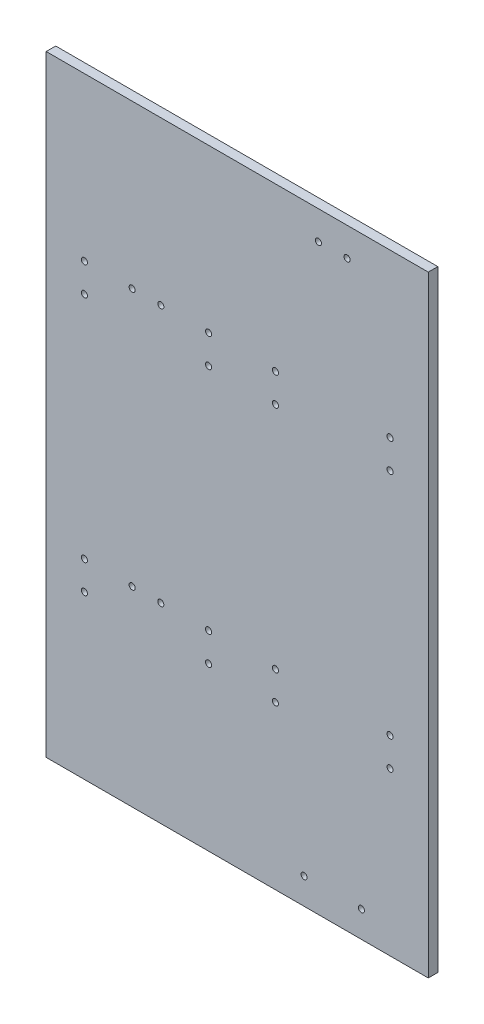
from build123d import *

# Parameters (mm, degrees)
SKETCH1_W           = 200
SKETCH1_H           = 320
BOSS_EXTRUDE1_DEPTH = 5
CUT_EXTRUDE1_REACH  = 7
SKETCH2_R           = 1.6
CUT_EXTRUDE2_REACH  = 7
SKETCH3_R           = 1.6
CUT_EXTRUDE3_REACH  = 7
SKETCH4_R           = 1.6
CUT_EXTRUDE4_REACH  = 7
SKETCH5_R           = 1.6
CUT_EXTRUDE5_REACH  = 7
SKETCH6_R           = 1.6


with BuildPart() as part:
    # Sketch1 → Boss-Extrude1 (new body)
    with BuildSketch(Plane.XY):
        Rectangle(SKETCH1_W, SKETCH1_H)
    extrude(amount=BOSS_EXTRUDE1_DEPTH)

    # Sketch2 → Cut-Extrude1 (cut, up to next)
    with BuildSketch(Plane(origin=(0, 0, 0), x_dir=(-1, 0, 0), z_dir=(0, 0, -1)), mode=Mode.PRIVATE) as cut_extrude1_sk1:
        with Locations((-80, 75)):
            Circle(SKETCH2_R)
    cut_extrude1_tool1 = extrude(cut_extrude1_sk1.sketch, amount=-CUT_EXTRUDE1_REACH, mode=Mode.PRIVATE) & part.part
    add(cut_extrude1_tool1.solids().sort_by_distance((80, 75, 0))[0], mode=Mode.SUBTRACT)
    # Sketch2 → Cut-Extrude1 (cut, up to next)
    with BuildSketch(Plane(origin=(0, 0, 0), x_dir=(-1, 0, 0), z_dir=(0, 0, -1)), mode=Mode.PRIVATE) as cut_extrude1_sk2:
        with Locations((-80, 60)):
            Circle(SKETCH2_R)
    cut_extrude1_tool2 = extrude(cut_extrude1_sk2.sketch, amount=-CUT_EXTRUDE1_REACH, mode=Mode.PRIVATE) & part.part
    add(cut_extrude1_tool2.solids().sort_by_distance((80, 60, 0))[0], mode=Mode.SUBTRACT)
    # Sketch2 → Cut-Extrude1 (cut, up to next)
    with BuildSketch(Plane(origin=(0, 0, 0), x_dir=(-1, 0, 0), z_dir=(0, 0, -1)), mode=Mode.PRIVATE) as cut_extrude1_sk3:
        with Locations((-80, -60)):
            Circle(SKETCH2_R)
    cut_extrude1_tool3 = extrude(cut_extrude1_sk3.sketch, amount=-CUT_EXTRUDE1_REACH, mode=Mode.PRIVATE) & part.part
    add(cut_extrude1_tool3.solids().sort_by_distance((80, -60, 0))[0], mode=Mode.SUBTRACT)
    # Sketch2 → Cut-Extrude1 (cut, up to next)
    with BuildSketch(Plane(origin=(0, 0, 0), x_dir=(-1, 0, 0), z_dir=(0, 0, -1)), mode=Mode.PRIVATE) as cut_extrude1_sk4:
        with Locations((-80, -75)):
            Circle(SKETCH2_R)
    cut_extrude1_tool4 = extrude(cut_extrude1_sk4.sketch, amount=-CUT_EXTRUDE1_REACH, mode=Mode.PRIVATE) & part.part
    add(cut_extrude1_tool4.solids().sort_by_distance((80, -75, 0))[0], mode=Mode.SUBTRACT)
    # Sketch2 → Cut-Extrude1 (cut, up to next)
    with BuildSketch(Plane(origin=(0, 0, 0), x_dir=(-1, 0, 0), z_dir=(0, 0, -1)), mode=Mode.PRIVATE) as cut_extrude1_sk5:
        with Locations((-20, -75)):
            Circle(SKETCH2_R)
    cut_extrude1_tool5 = extrude(cut_extrude1_sk5.sketch, amount=-CUT_EXTRUDE1_REACH, mode=Mode.PRIVATE) & part.part
    add(cut_extrude1_tool5.solids().sort_by_distance((20, -75, 0))[0], mode=Mode.SUBTRACT)
    # Sketch2 → Cut-Extrude1 (cut, up to next)
    with BuildSketch(Plane(origin=(0, 0, 0), x_dir=(-1, 0, 0), z_dir=(0, 0, -1)), mode=Mode.PRIVATE) as cut_extrude1_sk6:
        with Locations((-20, -60)):
            Circle(SKETCH2_R)
    cut_extrude1_tool6 = extrude(cut_extrude1_sk6.sketch, amount=-CUT_EXTRUDE1_REACH, mode=Mode.PRIVATE) & part.part
    add(cut_extrude1_tool6.solids().sort_by_distance((20, -60, 0))[0], mode=Mode.SUBTRACT)
    # Sketch2 → Cut-Extrude1 (cut, up to next)
    with BuildSketch(Plane(origin=(0, 0, 0), x_dir=(-1, 0, 0), z_dir=(0, 0, -1)), mode=Mode.PRIVATE) as cut_extrude1_sk7:
        with Locations((-20, 60)):
            Circle(SKETCH2_R)
    cut_extrude1_tool7 = extrude(cut_extrude1_sk7.sketch, amount=-CUT_EXTRUDE1_REACH, mode=Mode.PRIVATE) & part.part
    add(cut_extrude1_tool7.solids().sort_by_distance((20, 60, 0))[0], mode=Mode.SUBTRACT)
    # Sketch2 → Cut-Extrude1 (cut, up to next)
    with BuildSketch(Plane(origin=(0, 0, 0), x_dir=(-1, 0, 0), z_dir=(0, 0, -1)), mode=Mode.PRIVATE) as cut_extrude1_sk8:
        with Locations((-20, 75)):
            Circle(SKETCH2_R)
    cut_extrude1_tool8 = extrude(cut_extrude1_sk8.sketch, amount=-CUT_EXTRUDE1_REACH, mode=Mode.PRIVATE) & part.part
    add(cut_extrude1_tool8.solids().sort_by_distance((20, 75, 0))[0], mode=Mode.SUBTRACT)

    # Sketch3 → Cut-Extrude2 (cut, up to next)
    with BuildSketch(Plane(origin=(0, 0, 0), x_dir=(-1, 0, 0), z_dir=(0, 0, -1)), mode=Mode.PRIVATE) as cut_extrude2_sk1:
        with Locations((80, 75)):
            Circle(SKETCH3_R)
    cut_extrude2_tool1 = extrude(cut_extrude2_sk1.sketch, amount=-CUT_EXTRUDE2_REACH, mode=Mode.PRIVATE) & part.part
    add(cut_extrude2_tool1.solids().sort_by_distance((-80, 75, 0))[0], mode=Mode.SUBTRACT)
    # Sketch3 → Cut-Extrude2 (cut, up to next)
    with BuildSketch(Plane(origin=(0, 0, 0), x_dir=(-1, 0, 0), z_dir=(0, 0, -1)), mode=Mode.PRIVATE) as cut_extrude2_sk2:
        with Locations((80, 60)):
            Circle(SKETCH3_R)
    cut_extrude2_tool2 = extrude(cut_extrude2_sk2.sketch, amount=-CUT_EXTRUDE2_REACH, mode=Mode.PRIVATE) & part.part
    add(cut_extrude2_tool2.solids().sort_by_distance((-80, 60, 0))[0], mode=Mode.SUBTRACT)
    # Sketch3 → Cut-Extrude2 (cut, up to next)
    with BuildSketch(Plane(origin=(0, 0, 0), x_dir=(-1, 0, 0), z_dir=(0, 0, -1)), mode=Mode.PRIVATE) as cut_extrude2_sk3:
        with Locations((80, -60)):
            Circle(SKETCH3_R)
    cut_extrude2_tool3 = extrude(cut_extrude2_sk3.sketch, amount=-CUT_EXTRUDE2_REACH, mode=Mode.PRIVATE) & part.part
    add(cut_extrude2_tool3.solids().sort_by_distance((-80, -60, 0))[0], mode=Mode.SUBTRACT)
    # Sketch3 → Cut-Extrude2 (cut, up to next)
    with BuildSketch(Plane(origin=(0, 0, 0), x_dir=(-1, 0, 0), z_dir=(0, 0, -1)), mode=Mode.PRIVATE) as cut_extrude2_sk4:
        with Locations((80, -75)):
            Circle(SKETCH3_R)
    cut_extrude2_tool4 = extrude(cut_extrude2_sk4.sketch, amount=-CUT_EXTRUDE2_REACH, mode=Mode.PRIVATE) & part.part
    add(cut_extrude2_tool4.solids().sort_by_distance((-80, -75, 0))[0], mode=Mode.SUBTRACT)
    # Sketch3 → Cut-Extrude2 (cut, up to next)
    with BuildSketch(Plane(origin=(0, 0, 0), x_dir=(-1, 0, 0), z_dir=(0, 0, -1)), mode=Mode.PRIVATE) as cut_extrude2_sk5:
        with Locations((15, 60)):
            Circle(SKETCH3_R)
    cut_extrude2_tool5 = extrude(cut_extrude2_sk5.sketch, amount=-CUT_EXTRUDE2_REACH, mode=Mode.PRIVATE) & part.part
    add(cut_extrude2_tool5.solids().sort_by_distance((-15, 60, 0))[0], mode=Mode.SUBTRACT)
    # Sketch3 → Cut-Extrude2 (cut, up to next)
    with BuildSketch(Plane(origin=(0, 0, 0), x_dir=(-1, 0, 0), z_dir=(0, 0, -1)), mode=Mode.PRIVATE) as cut_extrude2_sk6:
        with Locations((15, -75)):
            Circle(SKETCH3_R)
    cut_extrude2_tool6 = extrude(cut_extrude2_sk6.sketch, amount=-CUT_EXTRUDE2_REACH, mode=Mode.PRIVATE) & part.part
    add(cut_extrude2_tool6.solids().sort_by_distance((-15, -75, 0))[0], mode=Mode.SUBTRACT)
    # Sketch3 → Cut-Extrude2 (cut, up to next)
    with BuildSketch(Plane(origin=(0, 0, 0), x_dir=(-1, 0, 0), z_dir=(0, 0, -1)), mode=Mode.PRIVATE) as cut_extrude2_sk7:
        with Locations((15, -60)):
            Circle(SKETCH3_R)
    cut_extrude2_tool7 = extrude(cut_extrude2_sk7.sketch, amount=-CUT_EXTRUDE2_REACH, mode=Mode.PRIVATE) & part.part
    add(cut_extrude2_tool7.solids().sort_by_distance((-15, -60, 0))[0], mode=Mode.SUBTRACT)
    # Sketch3 → Cut-Extrude2 (cut, up to next)
    with BuildSketch(Plane(origin=(0, 0, 0), x_dir=(-1, 0, 0), z_dir=(0, 0, -1)), mode=Mode.PRIVATE) as cut_extrude2_sk8:
        with Locations((15, 75)):
            Circle(SKETCH3_R)
    cut_extrude2_tool8 = extrude(cut_extrude2_sk8.sketch, amount=-CUT_EXTRUDE2_REACH, mode=Mode.PRIVATE) & part.part
    add(cut_extrude2_tool8.solids().sort_by_distance((-15, 75, 0))[0], mode=Mode.SUBTRACT)

    # Sketch4 → Cut-Extrude3 (cut, up to next)
    with BuildSketch(Plane.XY.offset(5), mode=Mode.PRIVATE) as cut_extrude3_sk1:
        with Locations((42.5, 145)):
            Circle(SKETCH4_R)
    cut_extrude3_tool1 = extrude(cut_extrude3_sk1.sketch, amount=-CUT_EXTRUDE3_REACH, mode=Mode.PRIVATE) & part.part
    add(cut_extrude3_tool1.solids().sort_by_distance((42.5, 145, 5))[0], mode=Mode.SUBTRACT)
    # Sketch4 → Cut-Extrude3 (cut, up to next)
    with BuildSketch(Plane.XY.offset(5), mode=Mode.PRIVATE) as cut_extrude3_sk2:
        with Locations((57.5, 145)):
            Circle(SKETCH4_R)
    cut_extrude3_tool2 = extrude(cut_extrude3_sk2.sketch, amount=-CUT_EXTRUDE3_REACH, mode=Mode.PRIVATE) & part.part
    add(cut_extrude3_tool2.solids().sort_by_distance((57.5, 145, 5))[0], mode=Mode.SUBTRACT)

    # Sketch5 → Cut-Extrude4 (cut, up to next)
    with BuildSketch(Plane(origin=(0, 0, 0), x_dir=(-1, 0, 0), z_dir=(0, 0, -1)), mode=Mode.PRIVATE) as cut_extrude4_sk1:
        with Locations((40, 75)):
            Circle(SKETCH5_R)
    cut_extrude4_tool1 = extrude(cut_extrude4_sk1.sketch, amount=-CUT_EXTRUDE4_REACH, mode=Mode.PRIVATE) & part.part
    add(cut_extrude4_tool1.solids().sort_by_distance((-40, 75, 0))[0], mode=Mode.SUBTRACT)
    # Sketch5 → Cut-Extrude4 (cut, up to next)
    with BuildSketch(Plane(origin=(0, 0, 0), x_dir=(-1, 0, 0), z_dir=(0, 0, -1)), mode=Mode.PRIVATE) as cut_extrude4_sk2:
        with Locations((55, 75)):
            Circle(SKETCH5_R)
    cut_extrude4_tool2 = extrude(cut_extrude4_sk2.sketch, amount=-CUT_EXTRUDE4_REACH, mode=Mode.PRIVATE) & part.part
    add(cut_extrude4_tool2.solids().sort_by_distance((-55, 75, 0))[0], mode=Mode.SUBTRACT)
    # Sketch5 → Cut-Extrude4 (cut, up to next)
    with BuildSketch(Plane(origin=(0, 0, 0), x_dir=(-1, 0, 0), z_dir=(0, 0, -1)), mode=Mode.PRIVATE) as cut_extrude4_sk3:
        with Locations((40, -60)):
            Circle(SKETCH5_R)
    cut_extrude4_tool3 = extrude(cut_extrude4_sk3.sketch, amount=-CUT_EXTRUDE4_REACH, mode=Mode.PRIVATE) & part.part
    add(cut_extrude4_tool3.solids().sort_by_distance((-40, -60, 0))[0], mode=Mode.SUBTRACT)
    # Sketch5 → Cut-Extrude4 (cut, up to next)
    with BuildSketch(Plane(origin=(0, 0, 0), x_dir=(-1, 0, 0), z_dir=(0, 0, -1)), mode=Mode.PRIVATE) as cut_extrude4_sk4:
        with Locations((55, -60)):
            Circle(SKETCH5_R)
    cut_extrude4_tool4 = extrude(cut_extrude4_sk4.sketch, amount=-CUT_EXTRUDE4_REACH, mode=Mode.PRIVATE) & part.part
    add(cut_extrude4_tool4.solids().sort_by_distance((-55, -60, 0))[0], mode=Mode.SUBTRACT)

    # Sketch6 → Cut-Extrude5 (cut, up to next)
    with BuildSketch(Plane(origin=(0, 0, 0), x_dir=(-1, 0, 0), z_dir=(0, 0, -1)), mode=Mode.PRIVATE) as cut_extrude5_sk1:
        with Locations((-65, -146.25)):
            Circle(SKETCH6_R)
    cut_extrude5_tool1 = extrude(cut_extrude5_sk1.sketch, amount=-CUT_EXTRUDE5_REACH, mode=Mode.PRIVATE) & part.part
    add(cut_extrude5_tool1.solids().sort_by_distance((65, -146.25, 0))[0], mode=Mode.SUBTRACT)
    # Sketch6 → Cut-Extrude5 (cut, up to next)
    with BuildSketch(Plane(origin=(0, 0, 0), x_dir=(-1, 0, 0), z_dir=(0, 0, -1)), mode=Mode.PRIVATE) as cut_extrude5_sk2:
        with Locations((-35, -146.25)):
            Circle(SKETCH6_R)
    cut_extrude5_tool2 = extrude(cut_extrude5_sk2.sketch, amount=-CUT_EXTRUDE5_REACH, mode=Mode.PRIVATE) & part.part
    add(cut_extrude5_tool2.solids().sort_by_distance((35, -146.25, 0))[0], mode=Mode.SUBTRACT)


solid = part.part
